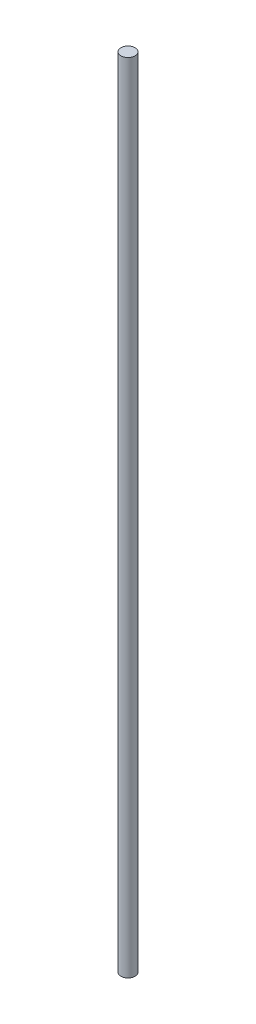
from build123d import *

# Parameters (mm, degrees)
ESQUISSE1_R        = 2.5
BOSS_EXTRU_1_DEPTH = 282


with BuildPart() as part:
    # Esquisse1 → Boss.-Extru.1 (new body)
    with BuildSketch(Plane(origin=(0, 0, 0), x_dir=(1, 0, 0), z_dir=(0, 1, 0))):
        Circle(ESQUISSE1_R)
    extrude(amount=BOSS_EXTRU_1_DEPTH)


solid = part.part
